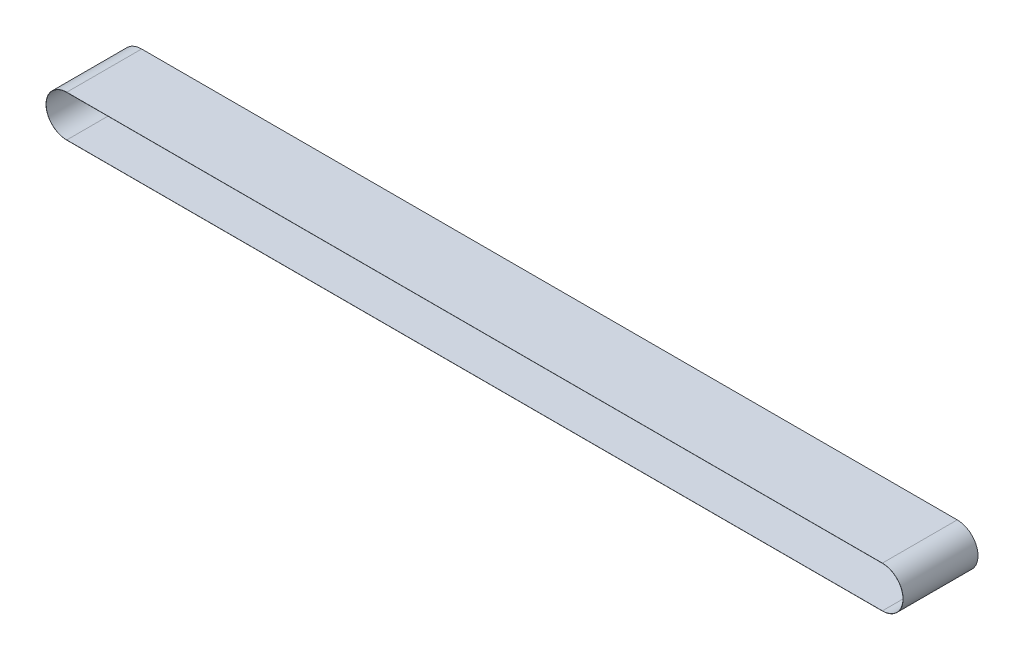
from build123d import *

# Parameters (mm, degrees)
EXTRU_MINCE1_DEPTH      = 25
EXTRU_MINCE1_DEPTH_BACK = 25


with BuildPart() as part:
    # Esquisse2 → Extru.-Mince1 (new body, two sides)
    with BuildSketch(Plane.XY) as extru_mince1_sk:
        with BuildLine():
            Line((-272.299999984, 13.855), (272.300004367, 13.855))
            ThreePointArc((272.300004367, 13.855), (286.155004367, -2.192e-06), (272.299999984, -13.855))
            Line((272.299999984, -13.855), (-272.300004367, -13.855))
            ThreePointArc((-272.300004367, -13.855), (-286.155004367, 2.192e-06), (-272.299999984, 13.855))
        make_face()
        with BuildLine():
            Line((-272.3, 13.755), (272.3, 13.755))
            ThreePointArc((272.3, 13.755), (286.055004367, 0), (272.3, -13.755))
            Line((272.3, -13.755), (-272.3, -13.755))
            ThreePointArc((-272.3, -13.755), (-286.055004367, 0), (-272.3, 13.755))
        make_face(mode=Mode.SUBTRACT)
    extrude(amount=EXTRU_MINCE1_DEPTH)
    extrude(extru_mince1_sk.sketch, amount=-EXTRU_MINCE1_DEPTH_BACK)


solid = part.part
